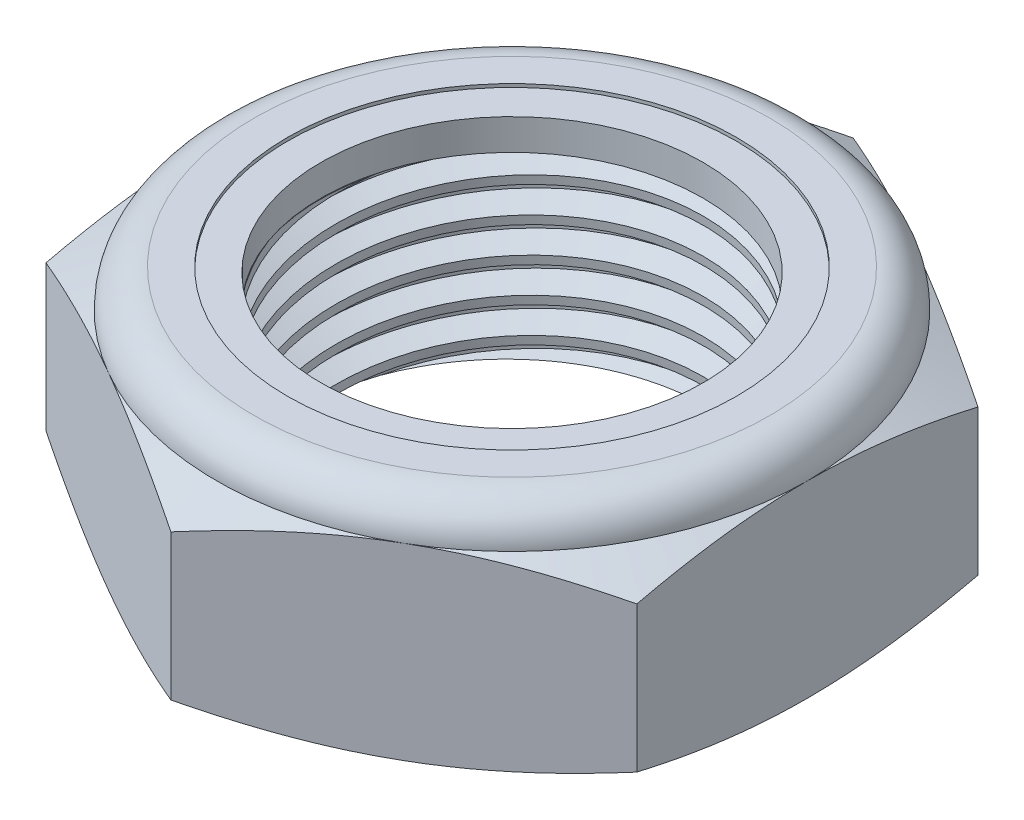
from build123d import *

# Parameters (mm, degrees)
EXTRUDE1_DEPTH      = 10.31875
SKETCH2_W           = 9.525
SKETCH2_H           = 10.31875
LPATTERN1_COUNT     = 7
LPATTERN1_PITCH     = 1.5875
LPATTERN1_COL_COUNT = 2
LPATTERN1_COL_PITCH = 1.5875


with BuildPart() as part:
    # Sketch1 → Extrude1 (new body)
    with BuildSketch(Plane(origin=(0, 0, 0), x_dir=(1, 0, 0), z_dir=(0, 1, 0))):
        Polygon((0, 15.58124039), (-13.49375, 7.790620195), (-13.49375, -7.790620195), (0, -15.58124039), (13.49375, -7.790620195), (13.49375, 7.790620195), align=None)
    extrude(amount=EXTRUDE1_DEPTH)

    # Sketch4 → Cut-Revolve2 (revolve, cut)
    with BuildSketch(Plane(origin=(0, 0, 0), x_dir=(0, 0, -1), z_dir=(1, 0, 0))):
        Polygon((0, 10.31875), (9.525, 10.31875), (8.726386191, 9.946350265), (8.726386191, 0.372399735), (9.525, 0), (0, 0), align=None)
    revolve(axis=Axis((0, 10.31875, 0), (0, 1, 0)), mode=Mode.SUBTRACT)


with BuildPart() as body_2:
    # Sketch2 → Revolve1 (revolve)
    with BuildSketch(Plane(origin=(0, 0, 0), x_dir=(0, 0, -1), z_dir=(1, 0, 0))):
        with Locations((4.7625, 5.159375)):
            Rectangle(SKETCH2_W, SKETCH2_H)
    revolve(axis=Axis((0, -9.525, 0), (0, 1, 0)))

    # Sketch3 → Cut-Revolve1 (revolve, cut)
    with BuildSketch(Plane(origin=(0, 0, 0), x_dir=(0, 0, -1), z_dir=(1, 0, 0))):
        Polygon((9.541479337, 10.120997951), (9.656834699, 8.736733609), (8.759344866, 9.159756107), (8.726386191, 9.555260205), align=None)
    cut_revolve1 = revolve(axis=Axis((0, 10.31875, 0.140817831), (0, -0.996545758, -0.08304548)), mode=Mode.SUBTRACT)

    # LPattern1: Cut-Revolve1 ×7
    with Locations(*[(0, -i * LPATTERN1_PITCH, 0) for i in range(1, LPATTERN1_COUNT)]):
        add(cut_revolve1, mode=Mode.SUBTRACT)

    # LPattern1 col: Cut-Revolve1 ×2
    with Locations(*[(0, i * LPATTERN1_COL_PITCH, 0) for i in range(1, LPATTERN1_COL_COUNT)]):
        add(cut_revolve1, mode=Mode.SUBTRACT)


with BuildPart() as part_1:
    add(part.part)

    # Combine1: cut body 2
    add(body_2.part, mode=Mode.SUBTRACT)

    # Sketch5 → Cut-Revolve3 (revolve, cut)
    with BuildSketch(Plane(origin=(0, 0, 0), x_dir=(0, 0, -1), z_dir=(1, 0, 0))):
        with BuildLine():
            Line((0, 0), (13.49375, 0))
            Line((13.49375, 0), (15.58124039, 0.973412755))
            Line((15.58124039, 0.973412755), (15.58124039, 7.625545578))
            Line((15.58124039, 7.625545578), (13.49375, 8.598958333))
            ThreePointArc((13.49375, 8.598958333), (12.990034683, 9.815034683), (11.773958333, 10.31875))
            Line((11.773958333, 10.31875), (11.773958333, 11.58875))
            Line((11.773958333, 11.58875), (16.85124039, 11.58875))
            Line((16.85124039, 11.58875), (16.85124039, -1.27))
            Line((16.85124039, -1.27), (0, -1.27))
            Line((0, -1.27), (0, 0))
        make_face()
    revolve(axis=Axis((0, 0, 0), (0, 1, 0)), mode=Mode.SUBTRACT)

    # Sketch6 → Cut-Revolve4 (revolve, cut)
    with BuildSketch(Plane(origin=(0, 0, 0), x_dir=(0, 0, -1), z_dir=(1, 0, 0))):
        with BuildLine():
            Line((0, 8.598958333), (13.34135, 8.598958333))
            ThreePointArc((13.34135, 8.598958333), (12.88227161, 9.70727161), (11.773958333, 10.16635))
            Line((11.773958333, 10.16635), (10.250172262, 10.16635))
            Line((10.250172262, 10.16635), (10.250172262, 11.58875))
            Line((10.250172262, 11.58875), (0, 11.58875))
            Line((0, 11.58875), (0, 8.598958333))
        make_face()
    revolve(axis=Axis((0, 11.58875, 0), (0, 1, 0)), mode=Mode.SUBTRACT)


with BuildPart() as body_2_2:
    # Sketch7 → Revolve2 (revolve)
    with BuildSketch(Plane(origin=(0, 0, 0), x_dir=(0, 0, -1), z_dir=(1, 0, 0))):
        with BuildLine():
            Line((8.726386191, 8.675158333), (13.263201815, 8.675158333))
            ThreePointArc((13.263201815, 8.675158333), (12.801096051, 9.679995195), (11.773958333, 10.09015))
            Line((11.773958333, 10.09015), (8.726386191, 10.09015))
            Line((8.726386191, 10.09015), (8.726386191, 8.675158333))
        make_face()
    revolve(axis=Axis((0, 8.675158333, 0), (0, 1, 0)))


solid = Compound([part_1.part, body_2_2.part])
